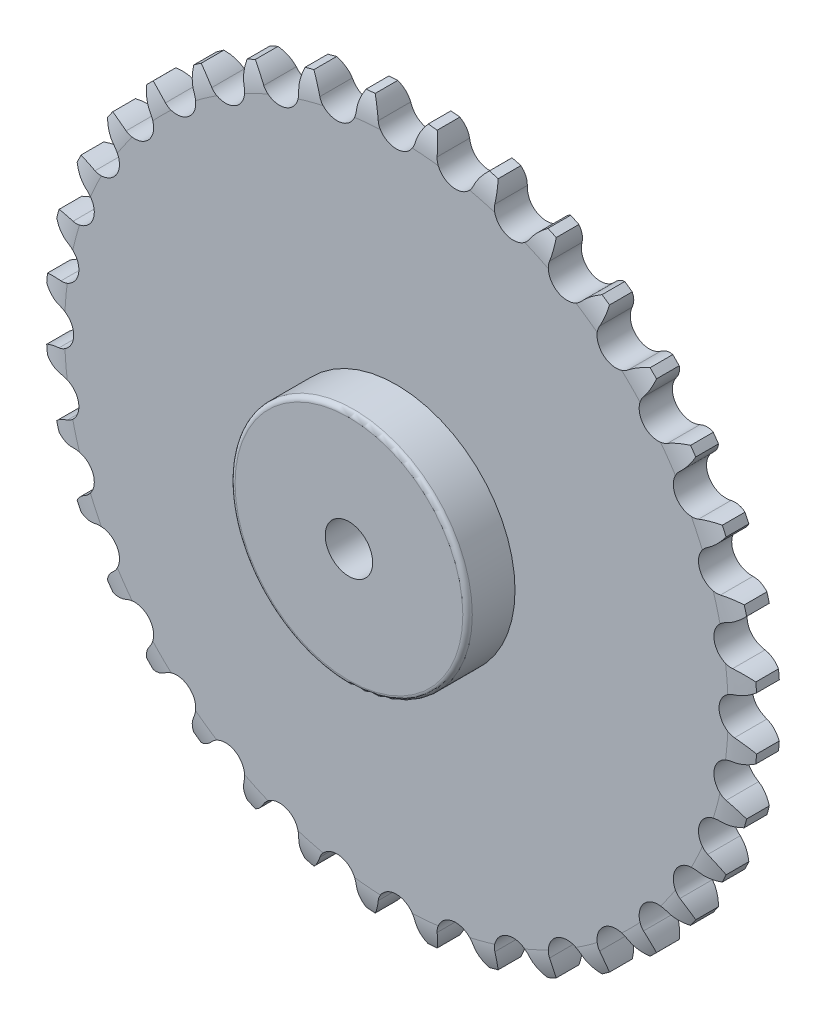
from build123d import *

# Parameters (mm, degrees)
SKETCH1_R           = 15
BOSS_EXTRUDE1_DEPTH = 3.5
SKETCH3_R           = 15
SKETCH3_R_2         = 5
BOSS_EXTRUDE2_DEPTH = 7
SKETCH4_R           = 25
SKETCH4_R_2         = 5
BOSS_EXTRUDE3_DEPTH = 10
FILLET1_R           = 1


with BuildPart() as part:
    # Sketch1 → Boss-Extrude1 (new body, symmetric)
    with BuildSketch(Plane.XY):
        with BuildLine():
            ThreePointArc((32.564099598, 67.561671215), (31.696369631, 67.973084028), (30.82344306, 68.373352689))
            ThreePointArc((30.82344306, 68.373352689), (29.262412427, 67.109599321), (28.015632923, 65.534978706))
            ThreePointArc((28.015632923, 65.534978706), (23.257369746, 63.899098213), (20.663852392, 68.210807988))
            ThreePointArc((20.663852392, 68.210807988), (20.720910503, 70.218451778), (20.337416667, 72.189954172))
            ThreePointArc((20.337416667, 72.189954172), (19.411428383, 72.444436972), (18.482257605, 72.687042544))
            ThreePointArc((18.482257605, 72.687042544), (17.164391004, 71.171418305), (16.209982883, 69.404218727))
            ThreePointArc((16.209982883, 69.404218727), (11.808076081, 66.966927205), (8.505239538, 70.762772858))
            ThreePointArc((8.505239538, 70.762772858), (8.212807123, 72.749824064), (7.492791622, 74.624781901))
            ThreePointArc((7.492791622, 74.624781901), (6.536680706, 74.714602357), (5.579498105, 74.792173393))
            ThreePointArc((5.579498105, 74.792173393), (4.544838245, 73.070729759), (3.911800715, 71.164646681))
            ThreePointArc((3.911800715, 71.164646681), (0, 68), (-3.911800715, 71.164646681))
            ThreePointArc((-3.911800715, 71.164646681), (-4.544838245, 73.070729759), (-5.579498105, 74.792173393))
            ThreePointArc((-5.579498105, 74.792173393), (-6.536680706, 74.714602357), (-7.492791622, 74.624781901))
            ThreePointArc((-7.492791622, 74.624781901), (-8.212807123, 72.749824064), (-8.505239538, 70.762772858))
            ThreePointArc((-8.505239538, 70.762772858), (-11.808076081, 66.966927205), (-16.209982883, 69.404218727))
            ThreePointArc((-16.209982883, 69.404218727), (-17.164391004, 71.171418305), (-18.482257605, 72.687042544))
            ThreePointArc((-18.482257605, 72.687042544), (-19.411428383, 72.444436972), (-20.337416667, 72.189954172))
            ThreePointArc((-20.337416667, 72.189954172), (-20.720910503, 70.218451778), (-20.663852392, 68.210807988))
            ThreePointArc((-20.663852392, 68.210807988), (-23.257369746, 63.899098213), (-28.015632923, 65.534978706))
            ThreePointArc((-28.015632923, 65.534978706), (-29.262412427, 67.109599321), (-30.82344306, 68.373352689))
            ThreePointArc((-30.82344306, 68.373352689), (-31.696369631, 67.973084028), (-32.564099598, 67.561671215))
            ThreePointArc((-32.564099598, 67.561671215), (-32.599419503, 65.553527367), (-32.194604547, 63.586292235))
            ThreePointArc((-32.194604547, 63.586292235), (-34, 58.889727457), (-38.970042134, 59.67449152))
            ThreePointArc((-38.970042134, 59.67449152), (-40.471310256, 61.008689121), (-42.228073796, 61.98217311))
            ThreePointArc((-42.228073796, 61.98217311), (-43.018232726, 61.436403322), (-43.80133884, 60.880561067))
            ThreePointArc((-43.80133884, 60.880561067), (-43.487411637, 58.896792198), (-42.747139934, 57.029739168))
            ThreePointArc((-42.747139934, 57.029739168), (-43.709557459, 52.091022132), (-48.740366335, 52.000825106))
            ThreePointArc((-48.740366335, 52.000825106), (-50.450507802, 53.054060774), (-52.349625877, 53.707696567))
            ThreePointArc((-52.349625877, 53.707696567), (-53.033008589, 53.033008589), (-53.707696567, 52.349625877))
            ThreePointArc((-53.707696567, 52.349625877), (-53.054060774, 50.450507802), (-52.000825106, 48.740366335))
            ThreePointArc((-52.000825106, 48.740366335), (-52.091022132, 43.709557459), (-57.029739168, 42.747139934))
            ThreePointArc((-57.029739168, 42.747139934), (-58.896792198, 43.487411637), (-60.880561067, 43.80133884))
            ThreePointArc((-60.880561067, 43.80133884), (-61.436403322, 43.018232726), (-61.98217311, 42.228073796))
            ThreePointArc((-61.98217311, 42.228073796), (-61.008689121, 40.471310256), (-59.67449152, 38.970042134))
            ThreePointArc((-59.67449152, 38.970042134), (-58.889727457, 34), (-63.586292235, 32.194604547))
            ThreePointArc((-63.586292235, 32.194604547), (-65.553527367, 32.599419503), (-67.561671215, 32.564099598))
            ThreePointArc((-67.561671215, 32.564099598), (-67.973084028, 31.696369631), (-68.373352689, 30.82344306))
            ThreePointArc((-68.373352689, 30.82344306), (-67.109599321, 29.262412427), (-65.534978706, 28.015632923))
            ThreePointArc((-65.534978706, 28.015632923), (-63.899098213, 23.257369746), (-68.210807988, 20.663852392))
            ThreePointArc((-68.210807988, 20.663852392), (-70.218451778, 20.720910503), (-72.189954172, 20.337416667))
            ThreePointArc((-72.189954172, 20.337416667), (-72.444436972, 19.411428383), (-72.687042544, 18.482257605))
            ThreePointArc((-72.687042544, 18.482257605), (-71.171418305, 17.164391004), (-69.404218727, 16.209982883))
            ThreePointArc((-69.404218727, 16.209982883), (-66.966927205, 11.808076081), (-70.762772858, 8.505239538))
            ThreePointArc((-70.762772858, 8.505239538), (-72.749824064, 8.212807123), (-74.624781901, 7.492791622))
            ThreePointArc((-74.624781901, 7.492791622), (-74.714602357, 6.536680706), (-74.792173393, 5.579498105))
            ThreePointArc((-74.792173393, 5.579498105), (-73.070729759, 4.544838245), (-71.164646681, 3.911800715))
            ThreePointArc((-71.164646681, 3.911800715), (-68, 0), (-71.164646681, -3.911800715))
            ThreePointArc((-71.164646681, -3.911800715), (-73.070729759, -4.544838245), (-74.792173393, -5.579498105))
            ThreePointArc((-74.792173393, -5.579498105), (-74.714602357, -6.536680706), (-74.624781901, -7.492791622))
            ThreePointArc((-74.624781901, -7.492791622), (-72.749824064, -8.212807123), (-70.762772858, -8.505239538))
            ThreePointArc((-70.762772858, -8.505239538), (-66.966927205, -11.808076081), (-69.404218727, -16.209982883))
            ThreePointArc((-69.404218727, -16.209982883), (-71.171418305, -17.164391004), (-72.687042544, -18.482257605))
            ThreePointArc((-72.687042544, -18.482257605), (-72.444436972, -19.411428383), (-72.189954172, -20.337416667))
            ThreePointArc((-72.189954172, -20.337416667), (-70.218451778, -20.720910503), (-68.210807988, -20.663852392))
            ThreePointArc((-68.210807988, -20.663852392), (-63.899098213, -23.257369746), (-65.534978706, -28.015632923))
            ThreePointArc((-65.534978706, -28.015632923), (-67.109599321, -29.262412427), (-68.373352689, -30.82344306))
            ThreePointArc((-68.373352689, -30.82344306), (-67.973084028, -31.696369631), (-67.561671215, -32.564099598))
            ThreePointArc((-67.561671215, -32.564099598), (-65.553527367, -32.599419503), (-63.586292235, -32.194604547))
            ThreePointArc((-63.586292235, -32.194604547), (-58.889727457, -34), (-59.67449152, -38.970042134))
            ThreePointArc((-59.67449152, -38.970042134), (-61.008689121, -40.471310256), (-61.98217311, -42.228073796))
            ThreePointArc((-61.98217311, -42.228073796), (-61.436403322, -43.018232726), (-60.880561067, -43.80133884))
            ThreePointArc((-60.880561067, -43.80133884), (-58.896792198, -43.487411637), (-57.029739168, -42.747139934))
            ThreePointArc((-57.029739168, -42.747139934), (-52.091022132, -43.709557459), (-52.000825106, -48.740366335))
            ThreePointArc((-52.000825106, -48.740366335), (-53.054060774, -50.450507802), (-53.707696567, -52.349625877))
            ThreePointArc((-53.707696567, -52.349625877), (-53.033008589, -53.033008589), (-52.349625877, -53.707696567))
            ThreePointArc((-52.349625877, -53.707696567), (-50.450507802, -53.054060774), (-48.740366335, -52.000825106))
            ThreePointArc((-48.740366335, -52.000825106), (-43.709557459, -52.091022132), (-42.747139934, -57.029739168))
            ThreePointArc((-42.747139934, -57.029739168), (-43.487411637, -58.896792198), (-43.80133884, -60.880561067))
            ThreePointArc((-43.80133884, -60.880561067), (-43.018232726, -61.436403322), (-42.228073796, -61.98217311))
            ThreePointArc((-42.228073796, -61.98217311), (-40.471310256, -61.008689121), (-38.970042134, -59.67449152))
            ThreePointArc((-38.970042134, -59.67449152), (-34, -58.889727457), (-32.194604547, -63.586292235))
            ThreePointArc((-32.194604547, -63.586292235), (-32.599419503, -65.553527367), (-32.564099598, -67.561671215))
            ThreePointArc((-32.564099598, -67.561671215), (-31.696369631, -67.973084028), (-30.82344306, -68.373352689))
            ThreePointArc((-30.82344306, -68.373352689), (-29.262412427, -67.109599321), (-28.015632923, -65.534978706))
            ThreePointArc((-28.015632923, -65.534978706), (-23.257369746, -63.899098213), (-20.663852392, -68.210807988))
            ThreePointArc((-20.663852392, -68.210807988), (-20.720910503, -70.218451778), (-20.337416667, -72.189954172))
            ThreePointArc((-20.337416667, -72.189954172), (-19.411428383, -72.444436972), (-18.482257605, -72.687042544))
            ThreePointArc((-18.482257605, -72.687042544), (-17.164391004, -71.171418305), (-16.209982883, -69.404218727))
            ThreePointArc((-16.209982883, -69.404218727), (-11.808076081, -66.966927205), (-8.505239538, -70.762772858))
            ThreePointArc((-8.505239538, -70.762772858), (-8.212807123, -72.749824064), (-7.492791622, -74.624781901))
            ThreePointArc((-7.492791622, -74.624781901), (-6.536680706, -74.714602357), (-5.579498105, -74.792173393))
            ThreePointArc((-5.579498105, -74.792173393), (-4.544838245, -73.070729759), (-3.911800715, -71.164646681))
            ThreePointArc((-3.911800715, -71.164646681), (0, -68), (3.911800715, -71.164646681))
            ThreePointArc((3.911800715, -71.164646681), (4.544838245, -73.070729759), (5.579498105, -74.792173393))
            ThreePointArc((5.579498105, -74.792173393), (6.536680706, -74.714602357), (7.492791622, -74.624781901))
            ThreePointArc((7.492791622, -74.624781901), (8.212807123, -72.749824064), (8.505239538, -70.762772858))
            ThreePointArc((8.505239538, -70.762772858), (11.808076081, -66.966927205), (16.209982883, -69.404218727))
            ThreePointArc((16.209982883, -69.404218727), (17.164391004, -71.171418305), (18.482257605, -72.687042544))
            ThreePointArc((18.482257605, -72.687042544), (19.411428383, -72.444436972), (20.337416667, -72.189954172))
            ThreePointArc((20.337416667, -72.189954172), (20.720910503, -70.218451778), (20.663852392, -68.210807988))
            ThreePointArc((20.663852392, -68.210807988), (23.257369746, -63.899098213), (28.015632923, -65.534978706))
            ThreePointArc((28.015632923, -65.534978706), (29.262412427, -67.109599321), (30.82344306, -68.373352689))
            ThreePointArc((30.82344306, -68.373352689), (31.696369631, -67.973084028), (32.564099598, -67.561671215))
            ThreePointArc((32.564099598, -67.561671215), (32.599419503, -65.553527367), (32.194604547, -63.586292235))
            ThreePointArc((32.194604547, -63.586292235), (34, -58.889727457), (38.970042134, -59.67449152))
            ThreePointArc((38.970042134, -59.67449152), (40.471310256, -61.008689121), (42.228073796, -61.98217311))
            ThreePointArc((42.228073796, -61.98217311), (43.018232726, -61.436403322), (43.80133884, -60.880561067))
            ThreePointArc((43.80133884, -60.880561067), (43.487411637, -58.896792198), (42.747139934, -57.029739168))
            ThreePointArc((42.747139934, -57.029739168), (43.709557459, -52.091022132), (48.740366335, -52.000825106))
            ThreePointArc((48.740366335, -52.000825106), (50.450507802, -53.054060774), (52.349625877, -53.707696567))
            ThreePointArc((52.349625877, -53.707696567), (53.033008589, -53.033008589), (53.707696567, -52.349625877))
            ThreePointArc((53.707696567, -52.349625877), (53.054060774, -50.450507802), (52.000825106, -48.740366335))
            ThreePointArc((52.000825106, -48.740366335), (52.091022132, -43.709557459), (57.029739168, -42.747139934))
            ThreePointArc((57.029739168, -42.747139934), (58.896792198, -43.487411637), (60.880561067, -43.80133884))
            ThreePointArc((60.880561067, -43.80133884), (61.436403322, -43.018232726), (61.98217311, -42.228073796))
            ThreePointArc((61.98217311, -42.228073796), (61.008689121, -40.471310256), (59.67449152, -38.970042134))
            ThreePointArc((59.67449152, -38.970042134), (58.889727457, -34), (63.586292235, -32.194604547))
            ThreePointArc((63.586292235, -32.194604547), (65.553527367, -32.599419503), (67.561671215, -32.564099598))
            ThreePointArc((67.561671215, -32.564099598), (67.973084028, -31.696369631), (68.373352689, -30.82344306))
            ThreePointArc((68.373352689, -30.82344306), (67.109599321, -29.262412427), (65.534978706, -28.015632923))
            ThreePointArc((65.534978706, -28.015632923), (63.899098213, -23.257369746), (68.210807988, -20.663852392))
            ThreePointArc((68.210807988, -20.663852392), (70.218451778, -20.720910503), (72.189954172, -20.337416667))
            ThreePointArc((72.189954172, -20.337416667), (72.444436972, -19.411428383), (72.687042544, -18.482257605))
            ThreePointArc((72.687042544, -18.482257605), (71.171418305, -17.164391004), (69.404218727, -16.209982883))
            ThreePointArc((69.404218727, -16.209982883), (66.966927205, -11.808076081), (70.762772858, -8.505239538))
            ThreePointArc((70.762772858, -8.505239538), (72.749824064, -8.212807123), (74.624781901, -7.492791622))
            ThreePointArc((74.624781901, -7.492791622), (74.714602357, -6.536680706), (74.792173393, -5.579498105))
            ThreePointArc((74.792173393, -5.579498105), (73.070729759, -4.544838245), (71.164646681, -3.911800715))
            ThreePointArc((71.164646681, -3.911800715), (68, 0), (71.164646681, 3.911800715))
            ThreePointArc((71.164646681, 3.911800715), (73.070729759, 4.544838245), (74.792173393, 5.579498105))
            ThreePointArc((74.792173393, 5.579498105), (74.714602357, 6.536680706), (74.624781901, 7.492791622))
            ThreePointArc((74.624781901, 7.492791622), (72.749824064, 8.212807123), (70.762772858, 8.505239538))
            ThreePointArc((70.762772858, 8.505239538), (66.966927205, 11.808076081), (69.404218727, 16.209982883))
            ThreePointArc((69.404218727, 16.209982883), (71.171418305, 17.164391004), (72.687042544, 18.482257605))
            ThreePointArc((72.687042544, 18.482257605), (72.444436972, 19.411428383), (72.189954172, 20.337416667))
            ThreePointArc((72.189954172, 20.337416667), (70.218451778, 20.720910503), (68.210807988, 20.663852392))
            ThreePointArc((68.210807988, 20.663852392), (63.899098213, 23.257369746), (65.534978706, 28.015632923))
            ThreePointArc((65.534978706, 28.015632923), (67.109599321, 29.262412427), (68.373352689, 30.82344306))
            ThreePointArc((68.373352689, 30.82344306), (67.973084028, 31.696369631), (67.561671215, 32.564099598))
            ThreePointArc((67.561671215, 32.564099598), (65.553527367, 32.599419503), (63.586292235, 32.194604547))
            ThreePointArc((63.586292235, 32.194604547), (58.889727457, 34), (59.67449152, 38.970042134))
            ThreePointArc((59.67449152, 38.970042134), (61.008689121, 40.471310256), (61.98217311, 42.228073796))
            ThreePointArc((61.98217311, 42.228073796), (61.436403322, 43.018232726), (60.880561067, 43.80133884))
            ThreePointArc((60.880561067, 43.80133884), (58.896792198, 43.487411637), (57.029739168, 42.747139934))
            ThreePointArc((57.029739168, 42.747139934), (52.091022132, 43.709557459), (52.000825106, 48.740366335))
            ThreePointArc((52.000825106, 48.740366335), (53.054060774, 50.450507802), (53.707696567, 52.349625877))
            ThreePointArc((53.707696567, 52.349625877), (53.033008589, 53.033008589), (52.349625877, 53.707696567))
            ThreePointArc((52.349625877, 53.707696567), (50.450507802, 53.054060774), (48.740366335, 52.000825106))
            ThreePointArc((48.740366335, 52.000825106), (43.709557459, 52.091022132), (42.747139934, 57.029739168))
            ThreePointArc((42.747139934, 57.029739168), (43.487411637, 58.896792198), (43.80133884, 60.880561067))
            ThreePointArc((43.80133884, 60.880561067), (43.018232726, 61.436403322), (42.228073796, 61.98217311))
            ThreePointArc((42.228073796, 61.98217311), (40.471310256, 61.008689121), (38.970042134, 59.67449152))
            ThreePointArc((38.970042134, 59.67449152), (34, 58.889727457), (32.194604547, 63.586292235))
            ThreePointArc((32.194604547, 63.586292235), (32.599419503, 65.553527367), (32.564099598, 67.561671215))
        make_face()
        Circle(SKETCH1_R, mode=Mode.SUBTRACT)
    extrude(amount=BOSS_EXTRUDE1_DEPTH, both=True)

    # Sketch2 → Cut-Revolve2 (revolve, cut)
    with BuildSketch(Plane(origin=(0, 0, 0), x_dir=(0, 0, -1), z_dir=(1, 0, 0))):
        with BuildLine():
            Line((4.5, 69.792173393), (3.5, 69.792173393))
            ThreePointArc((3.5, 69.792173393), (3.126937698, 72.886407818), (2, 75.792173393))
            Line((2, 75.792173393), (4.5, 75.792173393))
            Line((4.5, 75.792173393), (4.5, 69.792173393))
        make_face()
        with BuildLine():
            Line((-4.5, 75.792173393), (-2, 75.792173393))
            ThreePointArc((-2, 75.792173393), (-3.126937698, 72.886407818), (-3.5, 69.792173393))
            Line((-3.5, 69.792173393), (-4.5, 69.792173393))
            Line((-4.5, 69.792173393), (-4.5, 75.792173393))
        make_face()
    revolve(axis=Axis((0, 0, 3.5), (0, 0, -1)), mode=Mode.SUBTRACT)

    # Sketch3 → Boss-Extrude2 (add)
    with BuildSketch(Plane.XY.offset(3.5)):
        Circle(SKETCH3_R)
        Circle(SKETCH3_R_2, mode=Mode.SUBTRACT)
    extrude(amount=-BOSS_EXTRUDE2_DEPTH)

    # Sketch4 → Boss-Extrude3 (add)
    with BuildSketch(Plane.XY.offset(3.5)):
        Circle(SKETCH4_R)
        Circle(SKETCH4_R_2, mode=Mode.SUBTRACT)
    extrude(amount=BOSS_EXTRUDE3_DEPTH)

    # Fillet1
    fillet1_edges = [part.edges().sort_by_distance(p)[0] for p in [
        (-25, 0, 13.5),
    ]]
    fillet(fillet1_edges, radius=FILLET1_R)


solid = part.part
